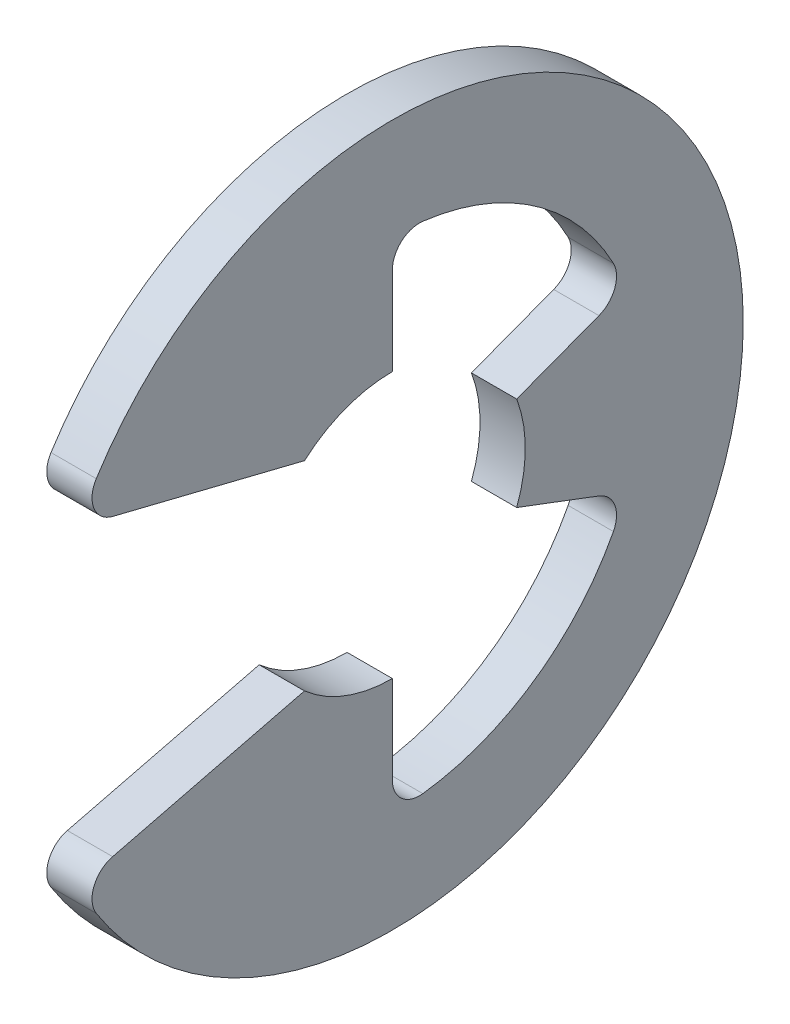
from build123d import *

# Parameters (mm, degrees)
EXTRUDE1_DEPTH = 0.35
FILLET1_R      = 0.42


with BuildPart() as part:
    # Sketch1 → Extrude1 (new body, symmetric)
    with BuildSketch(Plane(origin=(0, 0, 0), x_dir=(0, 0, -1), z_dir=(1, 0, 0))):
        with BuildLine():
            Line((-4.860103887, -2.410397313), (-1.359254736, -1.54125))
            ThreePointArc((-1.359254736, -1.54125), (-0.726552218, -1.922276482), (0, -2.055))
            Line((0, -2.055), (0, -3.860645161))
            ThreePointArc((0, -3.860645161), (2.194882217, -3.176015289), (3.611302871, -1.364944187))
            Line((3.611302871, -1.364944187), (1.922276482, -0.726552218))
            ThreePointArc((1.922276482, -0.726552218), (2.055, 0), (1.922276482, 0.726552218))
            Line((1.922276482, 0.726552218), (3.611302871, 1.364944187))
            ThreePointArc((3.611302871, 1.364944187), (2.194882217, 3.176015289), (0, 3.860645161))
            Line((0, 3.860645161), (0, 2.055))
            ThreePointArc((0, 2.055), (-0.726552218, 1.922276482), (-1.359254736, 1.54125))
            Line((-1.359254736, 1.54125), (-4.860103887, 2.410397313))
            ThreePointArc((-4.860103887, 2.410397313), (5.425, 0), (-4.860103887, -2.410397313))
        make_face()
    extrude(amount=EXTRUDE1_DEPTH, both=True)

    # Fillet1
    fillet1_edges = [part.edges().sort_by_distance(p)[0] for p in [
        (0, -2.410397313, 4.860103887),
        (0, -3.860645161, 0),
        (0, -1.364944187, -3.611302871),
        (0, 1.364944187, -3.611302871),
        (0, 3.860645161, 0),
        (0, 2.410397313, 4.860103887),
    ]]
    fillet(fillet1_edges, radius=FILLET1_R)


solid = part.part
